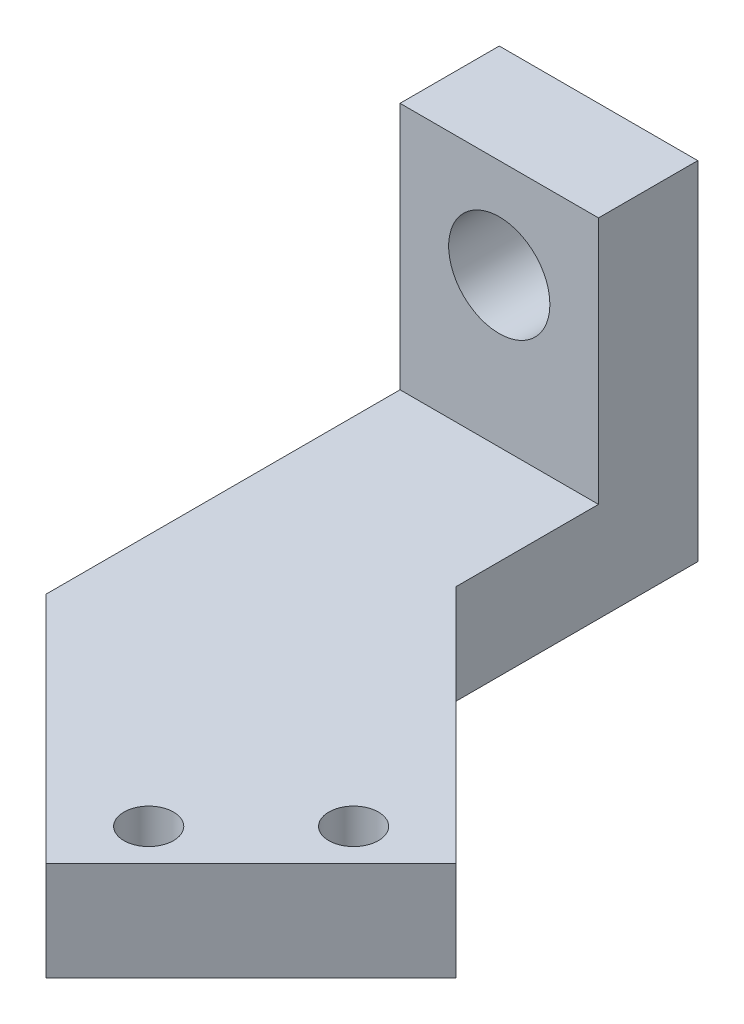
from build123d import *

# Parameters (mm, degrees)
SKETCH1_R           = 5.1
BOSS_EXTRUDE1_DEPTH = 10
BOSS_EXTRUDE3_DEPTH = 10
BOSS_EXTRUDE4_DEPTH = 10
CUT_EXTRUDE1_REACH  = 12
SKETCH7_R           = 2.5
CUT_EXTRUDE4_REACH  = 37


with BuildPart() as part:
    # Sketch1 → Boss-Extrude1 (new body)
    with BuildSketch(Plane.XY):
        Polygon((-10, -10), (-10, -15), (10, -15), (10, -10), (10, 10), (-10, 10), align=None)
        Circle(SKETCH1_R, mode=Mode.SUBTRACT)
    extrude(amount=BOSS_EXTRUDE1_DEPTH)

    # Sketch4 → Boss-Extrude3 (add)
    with BuildSketch(Plane.XZ.offset(15)):
        Polygon((-10, 10), (-10, 0), (10, 0), (10, 10), (14.5, 35), (14.5, 40), (-14.5, 40), (-14.5, 35), align=None)
    extrude(amount=BOSS_EXTRUDE3_DEPTH)

    # Sketch6 → Boss-Extrude4 (add)
    with BuildSketch(Plane(origin=(0, -15, 0), x_dir=(1, 0, 0), z_dir=(0, 1, 0))):
        Polygon((0, -35), (10.323759005, -24.676240995), (34.153257531, -48.505739521), (13.505739521, -69.153257531), (-10.323759005, -45.323759005), (-14.5, -40), (-5, -40), align=None)
    extrude(amount=-BOSS_EXTRUDE4_DEPTH)

    # Sketch7 → Cut-Extrude1 (cut, up to next)
    with BuildSketch(Plane(origin=(0, -15, 0), x_dir=(1, 0, 0), z_dir=(0, 1, 0)), mode=Mode.PRIVATE) as cut_extrude1_sk1:
        with Locations((15.432605499, -60.756364505)):
            Circle(SKETCH7_R)
    cut_extrude1_tool1 = extrude(cut_extrude1_sk1.sketch, amount=-CUT_EXTRUDE1_REACH, mode=Mode.PRIVATE) & part.part
    add(cut_extrude1_tool1.solids().sort_by_distance((15.432605, -15, 60.756365))[0], mode=Mode.SUBTRACT)
    # Sketch7 → Cut-Extrude1 (cut, up to next)
    with BuildSketch(Plane(origin=(0, -15, 0), x_dir=(1, 0, 0), z_dir=(0, 1, 0)), mode=Mode.PRIVATE) as cut_extrude1_sk2:
        with Locations((25.756364505, -50.432605499)):
            Circle(SKETCH7_R)
    cut_extrude1_tool2 = extrude(cut_extrude1_sk2.sketch, amount=-CUT_EXTRUDE1_REACH, mode=Mode.PRIVATE) & part.part
    add(cut_extrude1_tool2.solids().sort_by_distance((25.756365, -15, 50.432605))[0], mode=Mode.SUBTRACT)

    # Sketch8 → Cut-Extrude4 (cut, up to next)
    with BuildSketch(Plane.XZ.offset(25), mode=Mode.PRIVATE) as cut_extrude4_sk1:
        Polygon((10, 10), (10, 24.352481989), (13.150544827, 27.503026816), align=None)
    cut_extrude4_tool1 = extrude(cut_extrude4_sk1.sketch, amount=-CUT_EXTRUDE4_REACH, mode=Mode.PRIVATE) & part.part
    add(cut_extrude4_tool1.solids().sort_by_distance((11.050182, -25, 20.618503))[0], mode=Mode.SUBTRACT)
    # Sketch8 → Cut-Extrude4 (cut, up to next)
    with BuildSketch(Plane.XZ.offset(25), mode=Mode.PRIVATE) as cut_extrude4_sk2:
        Polygon((-14.5, 40), (-14.5, 35), (-10, 10), (-10, 45.647518011), (-10.323759005, 45.323759005), align=None)
    cut_extrude4_tool2 = extrude(cut_extrude4_sk2.sketch, amount=-CUT_EXTRUDE4_REACH, mode=Mode.PRIVATE) & part.part
    add(cut_extrude4_tool2.solids().sort_by_distance((-11.684358, -25, 31.470679))[0], mode=Mode.SUBTRACT)


solid = part.part
